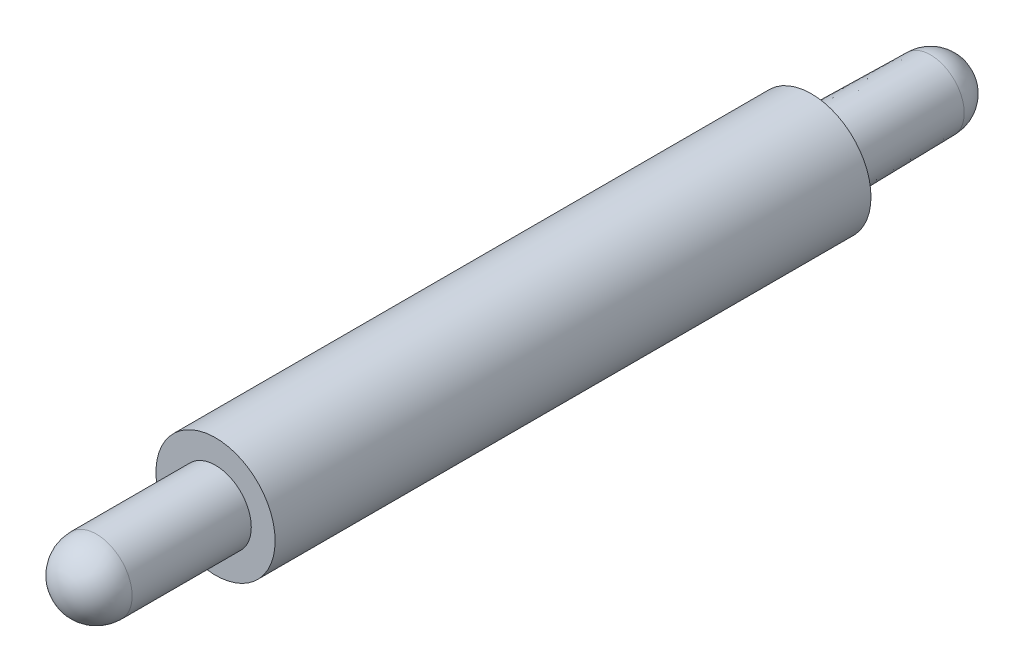
from build123d import *

# Parameters (mm, degrees)
SKETCH2_R           = 5
BOSS_EXTRUDE1_DEPTH = 50
SKETCH3_R           = 3
BOSS_EXTRUDE2_DEPTH = 10
BOSS_EXTRUDE2_TAPER = 1
SKETCH5_R           = 3
BOSS_EXTRUDE3_DEPTH = 10


with BuildPart() as part:
    # Sketch2 → Boss-Extrude1 (new body)
    with BuildSketch(Plane.XY):
        Circle(SKETCH2_R)
    extrude(amount=BOSS_EXTRUDE1_DEPTH)

    # Sketch3 → Boss-Extrude2 (add)
    with BuildSketch(Plane(origin=(0, 0, 0), x_dir=(-1, 0, 0), z_dir=(0, 0, -1))):
        Circle(SKETCH3_R)
    extrude(amount=BOSS_EXTRUDE2_DEPTH, taper=BOSS_EXTRUDE2_TAPER)

    # Sketch4 → Revolve1 (revolve)
    with BuildSketch(Plane(origin=(0, 0, -10), x_dir=(-1, 0, 0), z_dir=(0, 0, -1))):
        with BuildLine():
            Line((0, 2.825449351), (0, -2.825449351))
            ThreePointArc((0, -2.825449351), (-2.825449351, 0), (0, 2.825449351))
        make_face()
    revolve(axis=Axis((0, 2.825449351, -10), (0, -1, 0)))

    # Sketch5 → Boss-Extrude3 (add)
    with BuildSketch(Plane.XY.offset(50)):
        Circle(SKETCH5_R)
    extrude(amount=BOSS_EXTRUDE3_DEPTH)

    # Sketch6 → Revolve2 (revolve)
    with BuildSketch(Plane.XY.offset(60)):
        with BuildLine():
            Line((0, 3), (0, -3))
            ThreePointArc((0, -3), (-3, 0), (0, 3))
        make_face()
    revolve(axis=Axis((0, 3, 60), (0, -1, 0)))


solid = part.part
